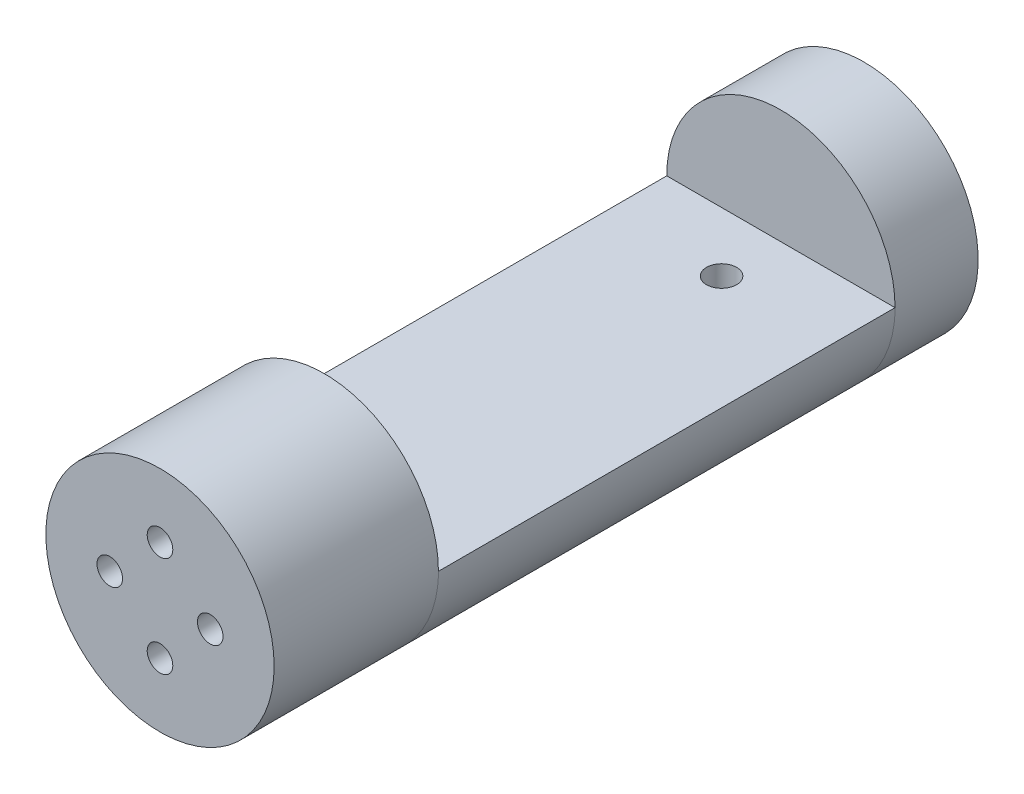
from build123d import *

# Parameters (mm, degrees)
SKETCH1_R           = 12.5
BOSS_EXTRUDE1_DEPTH = 17.99
SKETCH2_R           = 1.4
CUT_EXTRUDE1_DEPTH  = 8
BOSS_EXTRUDE3_DEPTH = 50
SKETCH6_R           = 12.5
BOSS_EXTRUDE4_DEPTH = 9.1
SKETCH7_R           = 1.65
CUT_EXTRUDE2_DEPTH  = 10


with BuildPart() as part:
    # Sketch1 → Boss-Extrude1 (new body)
    with BuildSketch(Plane.XY):
        Circle(SKETCH1_R)
    extrude(amount=BOSS_EXTRUDE1_DEPTH)

    # Sketch2 → Cut-Extrude1 (cut)
    with BuildSketch(Plane.XY.offset(17.99)):
        with Locations((0, -5.5)):
            Circle(SKETCH2_R)
        with Locations((-5.5, 0)):
            Circle(SKETCH2_R)
        with Locations((0, 5.5)):
            Circle(SKETCH2_R)
        with Locations((5.5, 0)):
            Circle(SKETCH2_R)
    extrude(amount=-CUT_EXTRUDE1_DEPTH, mode=Mode.SUBTRACT)

    # Sketch4 → Boss-Extrude3 (add)
    with BuildSketch(Plane(origin=(0, 0, 0), x_dir=(-1, 0, 0), z_dir=(0, 0, -1))):
        with BuildLine():
            Line((-12.5, 0), (12.5, 0))
            add(Edge.make_bspline(
                [(-12.5, 0), (-12.5, -12.5), (0, -12.5), (12.5, -12.5), (12.5, 0)],
                knots=[1.570796327, 1.570796327, 1.570796327, 3.141592654, 3.141592654, 4.71238898, 4.71238898, 4.71238898], degree=2, weights=[1, 0.707106781, 1, 0.707106781, 1]))
        make_face()
    extrude(amount=BOSS_EXTRUDE3_DEPTH)

    # Sketch6 → Boss-Extrude4 (add)
    with BuildSketch(Plane(origin=(0, 0, -50), x_dir=(-1, 0, 0), z_dir=(0, 0, -1))):
        Circle(SKETCH6_R)
    extrude(amount=BOSS_EXTRUDE4_DEPTH)

    # Sketch7 → Cut-Extrude2 (cut)
    with BuildSketch(Plane(origin=(0, 0, 0), x_dir=(1, 0, 0), z_dir=(0, 1, 0))):
        with Locations((0, 43.5)):
            Circle(SKETCH7_R)
        with Locations((0, 6.5)):
            Circle(SKETCH7_R)
    extrude(amount=-CUT_EXTRUDE2_DEPTH, mode=Mode.SUBTRACT)


solid = part.part
